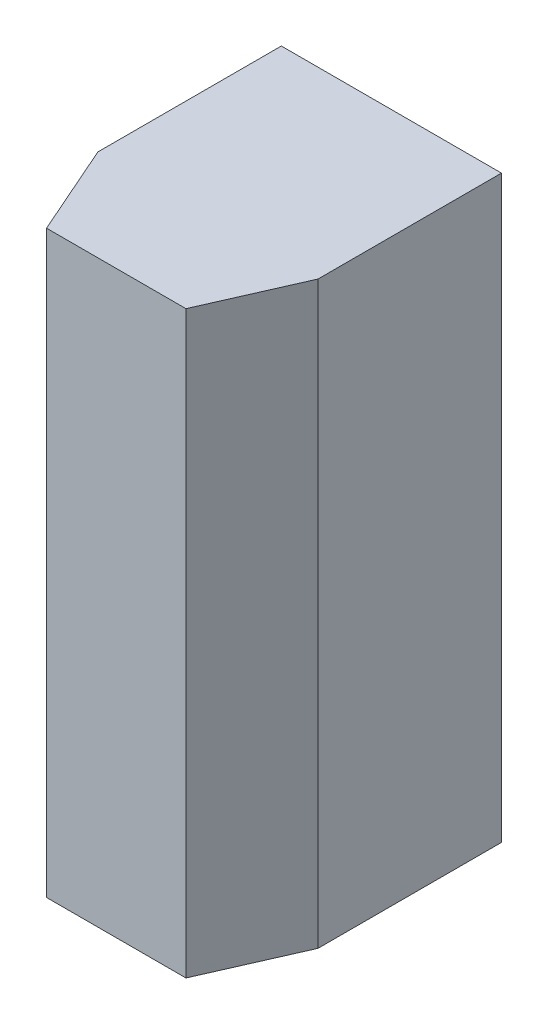
from build123d import *

# Parameters (mm, degrees)
SKETCH1_W           = 7.62
SKETCH1_H           = 20.066
BOSS_EXTRUDE1_DEPTH = 6.35
BOSS_EXTRUDE2_DEPTH = 20.066


with BuildPart() as part:
    # Sketch1 → Boss-Extrude1 (new body)
    with BuildSketch(Plane.XY):
        with Locations((3.81, 10.033)):
            Rectangle(SKETCH1_W, SKETCH1_H)
    extrude(amount=BOSS_EXTRUDE1_DEPTH)

    # Sketch4 → Boss-Extrude2 (add)
    with BuildSketch(Plane.XZ):
        Polygon((0, 6.35), (1.397, 9.525), (6.223, 9.525), (7.62, 6.35), align=None)
    extrude(amount=-BOSS_EXTRUDE2_DEPTH)


solid = part.part
